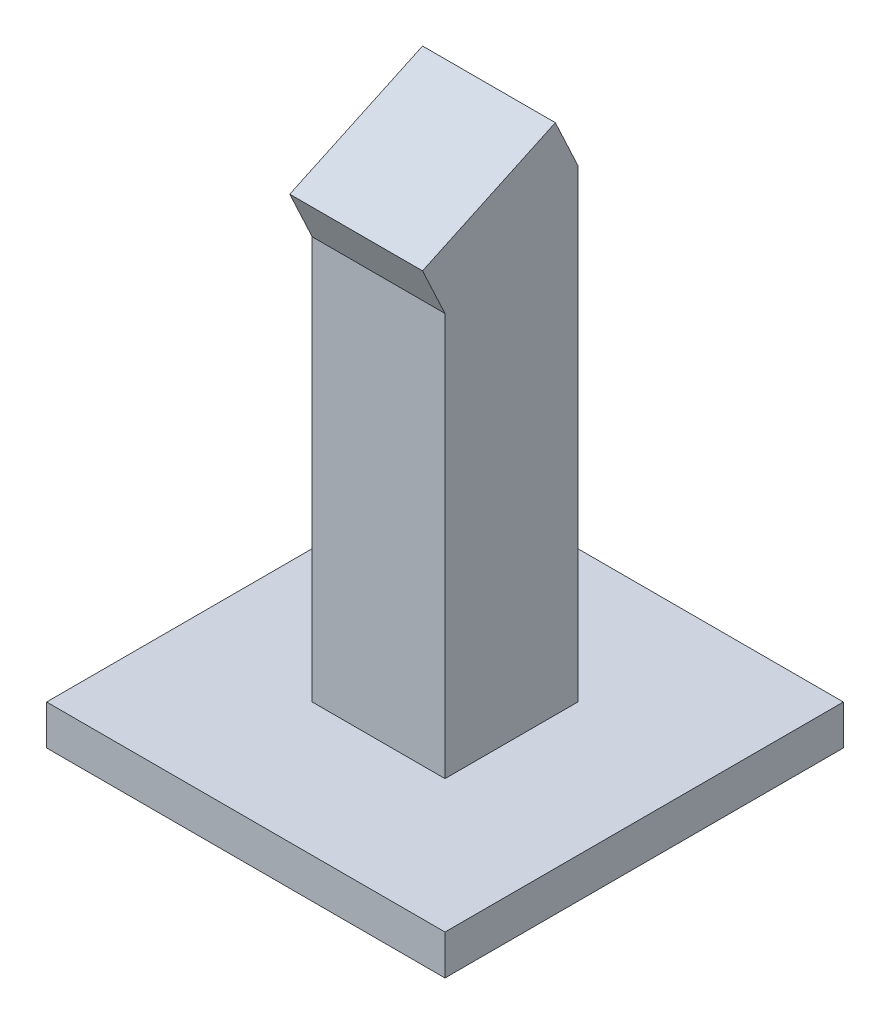
from build123d import *

# Parameters (mm, degrees)
SKETCH1_W           = 30
SKETCH1_H           = 30
BOSS_EXTRUDE1_DEPTH = 3
SKETCH2_W           = 10
SKETCH2_H           = 10
BOSS_EXTRUDE2_DEPTH = 35
CUT_EXTRUDE2_DEPTH  = 21
SKETCH5_W           = 10
SKETCH5_H           = 11.03377919
BOSS_EXTRUDE3_DEPTH = 4


with BuildPart() as part:
    # Sketch1 → Boss-Extrude1 (new body)
    with BuildSketch(Plane(origin=(0, 0, 0), x_dir=(1, 0, 0), z_dir=(0, 1, 0))):
        with Locations((15, -15)):
            Rectangle(SKETCH1_W, SKETCH1_H)
    extrude(amount=BOSS_EXTRUDE1_DEPTH)

    # Sketch2 → Boss-Extrude2 (add)
    with BuildSketch(Plane(origin=(0, 3, 0), x_dir=(1, 0, 0), z_dir=(0, 1, 0))):
        with Locations((15, -15)):
            Rectangle(SKETCH2_W, SKETCH2_H)
    extrude(amount=BOSS_EXTRUDE2_DEPTH)

    # Sketch3 → Cut-Extrude2 (cut, through all)
    with BuildSketch(Plane(origin=(20, 0, 0), x_dir=(0, 0, -1), z_dir=(1, 0, 0))):
        Polygon((-20, 38), (-10, 38), (-20, 33.336923418), align=None)
    extrude(amount=-CUT_EXTRUDE2_DEPTH, mode=Mode.SUBTRACT)

    # Sketch5 → Boss-Extrude3 (add)
    with BuildSketch(Plane(origin=(0, 35.0431868, 16.340906371), x_dir=(1, 0, 0), z_dir=(0, 0.906307787, 0.422618262))):
        with Locations((15, 1.479526481)):
            Rectangle(SKETCH5_W, SKETCH5_H)
    extrude(amount=BOSS_EXTRUDE3_DEPTH)


solid = part.part
